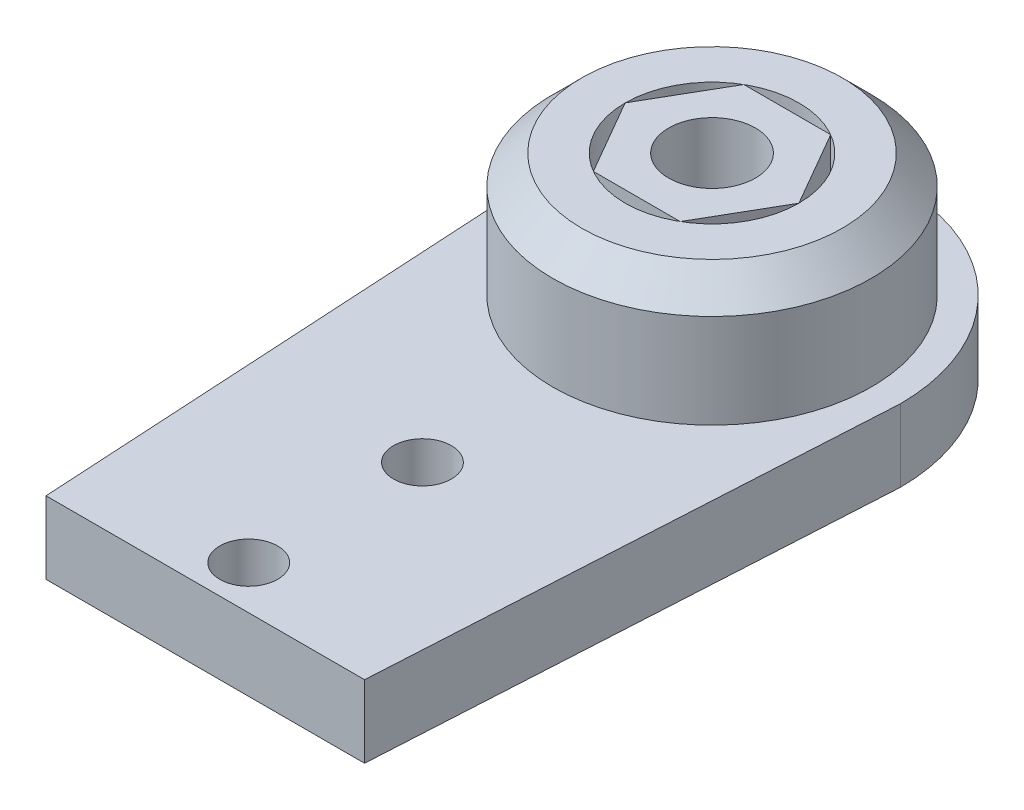
from build123d import *

# Parameters (mm, degrees)
SKETCH1_R           = 1
BOSS_EXTRUDE1_DEPTH = 2.5
SKETCH2_R           = 5.5
SKETCH2_R_2         = 3
BOSS_EXTRUDE3_DEPTH = 4.25
CUT_EXTRUDE1_REACH  = 4.5
SKETCH4_R           = 3
CHAMFER1_SIZE       = 1
SKETCH5_R           = 1.5
BOSS_EXTRUDE4_DEPTH = 2.5


with BuildPart() as part:
    # Sketch1 → Boss-Extrude1 (new body)
    with BuildSketch(Plane(origin=(0, 0, 0), x_dir=(1, 0, 0), z_dir=(0, 1, 0))):
        with BuildLine():
            ThreePointArc((6.5, 0), (0, 6.5), (-6.5, 0))
            Line((-6.5, 0), (-6.457689178, -0.740439382))
            Line((-6.457689178, -0.740439382), (-5.5, -17.5))
            Line((-5.5, -17.5), (5.5, -17.5))
            Line((5.5, -17.5), (6.457689178, -0.740439382))
            Line((6.457689178, -0.740439382), (6.5, 0))
        make_face()
        with Locations((0, -16)):
            Circle(SKETCH1_R, mode=Mode.SUBTRACT)
        with Locations((0, -10)):
            Circle(SKETCH1_R, mode=Mode.SUBTRACT)
    extrude(amount=BOSS_EXTRUDE1_DEPTH)

    # Sketch2 → Boss-Extrude3 (add)
    with BuildSketch(Plane(origin=(0, 2.5, 0), x_dir=(1, 0, 0), z_dir=(0, 1, 0))):
        Circle(SKETCH2_R)
        Circle(SKETCH2_R_2, mode=Mode.SUBTRACT)
    extrude(amount=BOSS_EXTRUDE3_DEPTH)

    # Sketch4 → Cut-Extrude1 (cut, up to next)
    with BuildSketch(Plane(origin=(0, 2.5, 0), x_dir=(1, 0, 0), z_dir=(0, 1, 0)), mode=Mode.PRIVATE) as cut_extrude1_sk1:
        Circle(SKETCH4_R)
    cut_extrude1_tool1 = extrude(cut_extrude1_sk1.sketch, amount=-CUT_EXTRUDE1_REACH, mode=Mode.PRIVATE) & part.part
    add(cut_extrude1_tool1.solids().sort_by_distance((0, 2.5, 0))[0], mode=Mode.SUBTRACT)

    # Chamfer1
    chamfer1_edges = [part.edges().sort_by_distance(p)[0] for p in [
        (-5.5, 6.75, 0),
    ]]
    chamfer(chamfer1_edges, length=CHAMFER1_SIZE)


with BuildPart() as body_2:
    # Sketch5 → Boss-Extrude4 (new body)
    with BuildSketch(Plane(origin=(0, 6.75, 0), x_dir=(1, 0, 0), z_dir=(0, 1, 0))):
        Polygon((3, 0), (1.5, 2.598076211), (-1.5, 2.598076211), (-3, 0), (-1.5, -2.598076211), (1.5, -2.598076211), align=None)
        Circle(SKETCH5_R, mode=Mode.SUBTRACT)
    extrude(amount=-BOSS_EXTRUDE4_DEPTH)


solid = Compound([part.part, body_2.part])
